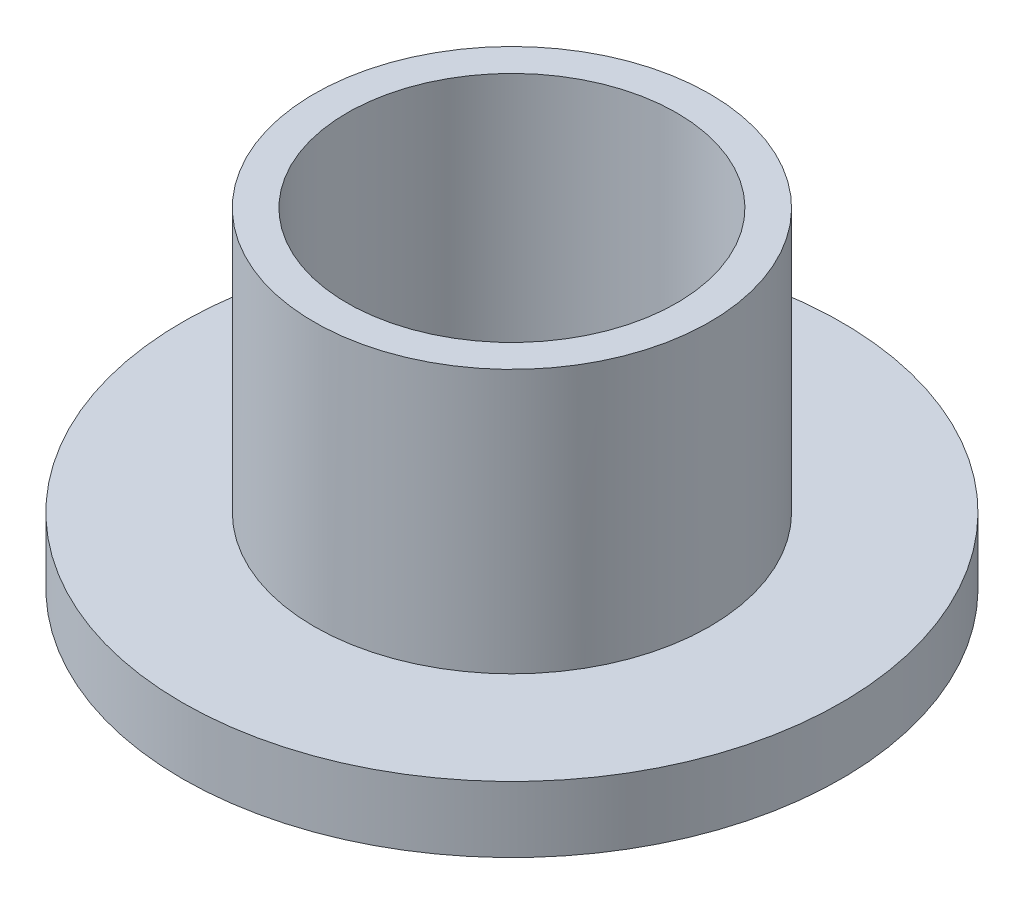
from build123d import *

# Parameters (mm, degrees)
SKETCH1_R           = 10
BOSS_EXTRUDE1_DEPTH = 2
SKETCH3_R           = 6
SKETCH3_R_2         = 5
BOSS_EXTRUDE2_DEPTH = 10
SKETCH4_R           = 5
CUT_EXTRUDE2_DEPTH  = 10


with BuildPart() as part:
    # Sketch1 → Boss-Extrude1 (new body)
    with BuildSketch(Plane(origin=(0, 0, 0), x_dir=(1, 0, 0), z_dir=(0, 1, 0))):
        Circle(SKETCH1_R)
    extrude(amount=BOSS_EXTRUDE1_DEPTH)

    # Sketch3 → Boss-Extrude2 (add)
    with BuildSketch(Plane.XZ):
        Circle(SKETCH3_R)
        Circle(SKETCH3_R_2, mode=Mode.SUBTRACT)
    extrude(amount=-BOSS_EXTRUDE2_DEPTH)

    # Sketch4 → Cut-Extrude2 (cut)
    with BuildSketch(Plane.XZ):
        Circle(SKETCH4_R)
    extrude(amount=-CUT_EXTRUDE2_DEPTH, mode=Mode.SUBTRACT)


solid = part.part
